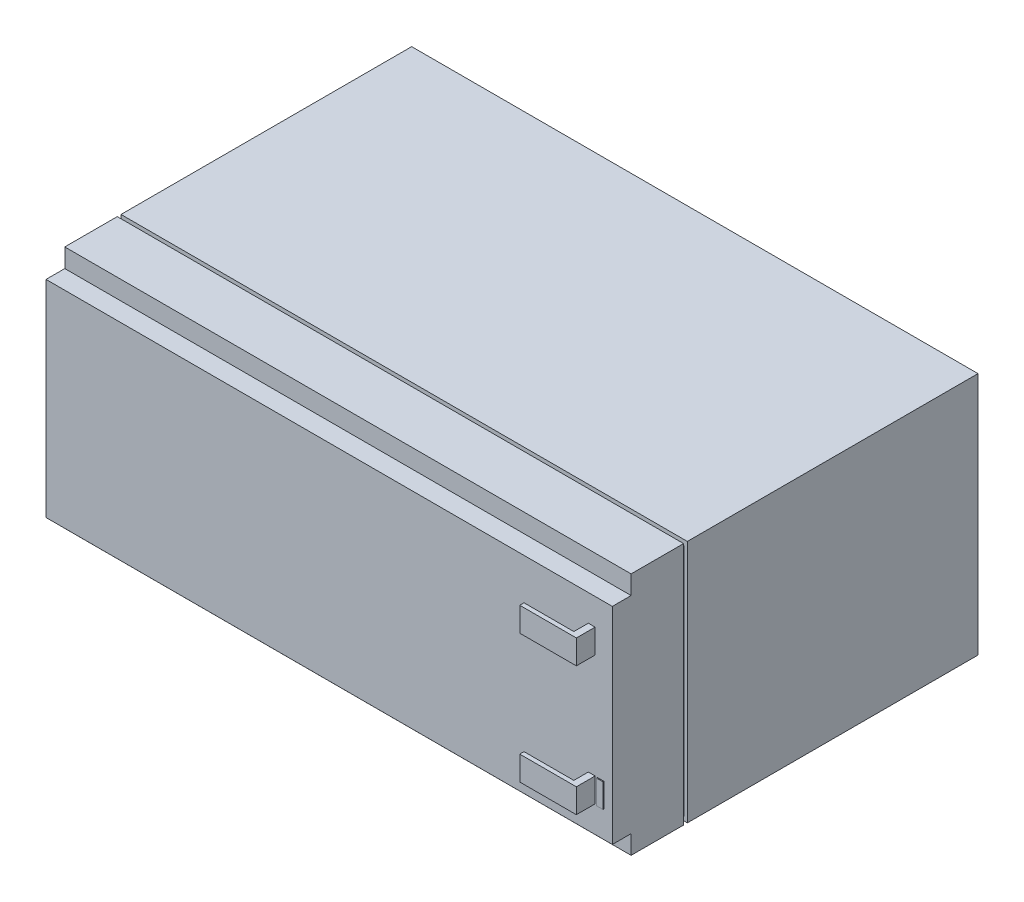
from build123d import *

# Parameters (mm, degrees)
ESQUISSE1_W             = 151
ESQUISSE1_H             = 65
BOSS_EXTRU_1_DEPTH      = 77.5
ESQUISSE3_W             = 148.454907539
ESQUISSE3_H             = 62.58067557
BOSS_EXTRU_4_DEPTH      = 1
ESQUISSE4_W             = 151
ESQUISSE4_H             = 65
BOSS_EXTRU_5_DEPTH      = 19
ESQUISSE5_W             = 5.004872729
ESQUISSE5_H             = 5.013872644
ESQUISSE5_H_2           = 5.00047463
ENL_V_MAT_EXTRU_1_DEPTH = 159
ESQUISSE6_W             = 15.091858935
ESQUISSE6_H             = 6.446271405
BOSS_EXTRU_6_DEPTH      = 5
ESQUISSE7_W             = 13.28107707
ESQUISSE7_H             = 3.860939677
ENL_V_MAT_EXTRU_2_DEPTH = 45
ESQUISSE8_W             = 1.776428529
ESQUISSE8_H             = 6.399764331
BOSS_EXTRU_7_DEPTH      = 0.25


with BuildPart() as part:
    # Esquisse1 → Boss.-Extru.1 (new body)
    with BuildSketch(Plane.XY):
        with Locations((75.5, 32.5)):
            Rectangle(ESQUISSE1_W, ESQUISSE1_H)
    extrude(amount=BOSS_EXTRU_1_DEPTH)

    # Esquisse3 → Boss.-Extru.4 (add)
    with BuildSketch(Plane.XY.offset(77.5)):
        with Locations((75.821779061, 32.317365634)):
            Rectangle(ESQUISSE3_W, ESQUISSE3_H)
    extrude(amount=BOSS_EXTRU_4_DEPTH)

    # Esquisse4 → Boss.-Extru.5 (add)
    with BuildSketch(Plane.XY.offset(78.5)):
        with Locations((75.5, 32.5)):
            Rectangle(ESQUISSE4_W, ESQUISSE4_H)
    extrude(amount=BOSS_EXTRU_5_DEPTH)

    # Esquisse5 → Enlèv. mat.-Extru.1 (cut)
    with BuildSketch(Plane(origin=(151, 0, 0), x_dir=(0, 0, -1), z_dir=(1, 0, 0))):
        with Locations((-94.997563636, 2.506936322)):
            Rectangle(ESQUISSE5_W, ESQUISSE5_H)
        with Locations((-94.997563636, 62.499762685)):
            Rectangle(ESQUISSE5_W, ESQUISSE5_H_2)
    extrude(amount=-ENL_V_MAT_EXTRU_1_DEPTH, mode=Mode.SUBTRACT)

    # Esquisse6 → Boss.-Extru.6 (add)
    with BuildSketch(Plane.XY.offset(97.5)):
        with Locations((138.863055981, 49.690815345)):
            Rectangle(ESQUISSE6_W, ESQUISSE6_H)
        with Locations((138.863055981, 15.32258267)):
            Rectangle(ESQUISSE6_W, ESQUISSE6_H)
    extrude(amount=BOSS_EXTRU_6_DEPTH)

    # Esquisse7 → Enlèv. mat.-Extru.2 (cut)
    with BuildSketch(Plane(origin=(0, 52.913951047, 0), x_dir=(1, 0, 0), z_dir=(0, 1, 0))):
        with Locations((137.957665049, -99.430469839)):
            Rectangle(ESQUISSE7_W, ESQUISSE7_H)
    extrude(amount=-ENL_V_MAT_EXTRU_2_DEPTH, mode=Mode.SUBTRACT)

    # Esquisse8 → Boss.-Extru.7 (add)
    with BuildSketch(Plane.XY.offset(97.5)):
        with Locations((147.886510026, 15.299329133)):
            Rectangle(ESQUISSE8_W, ESQUISSE8_H)
    extrude(amount=BOSS_EXTRU_7_DEPTH)


solid = part.part
